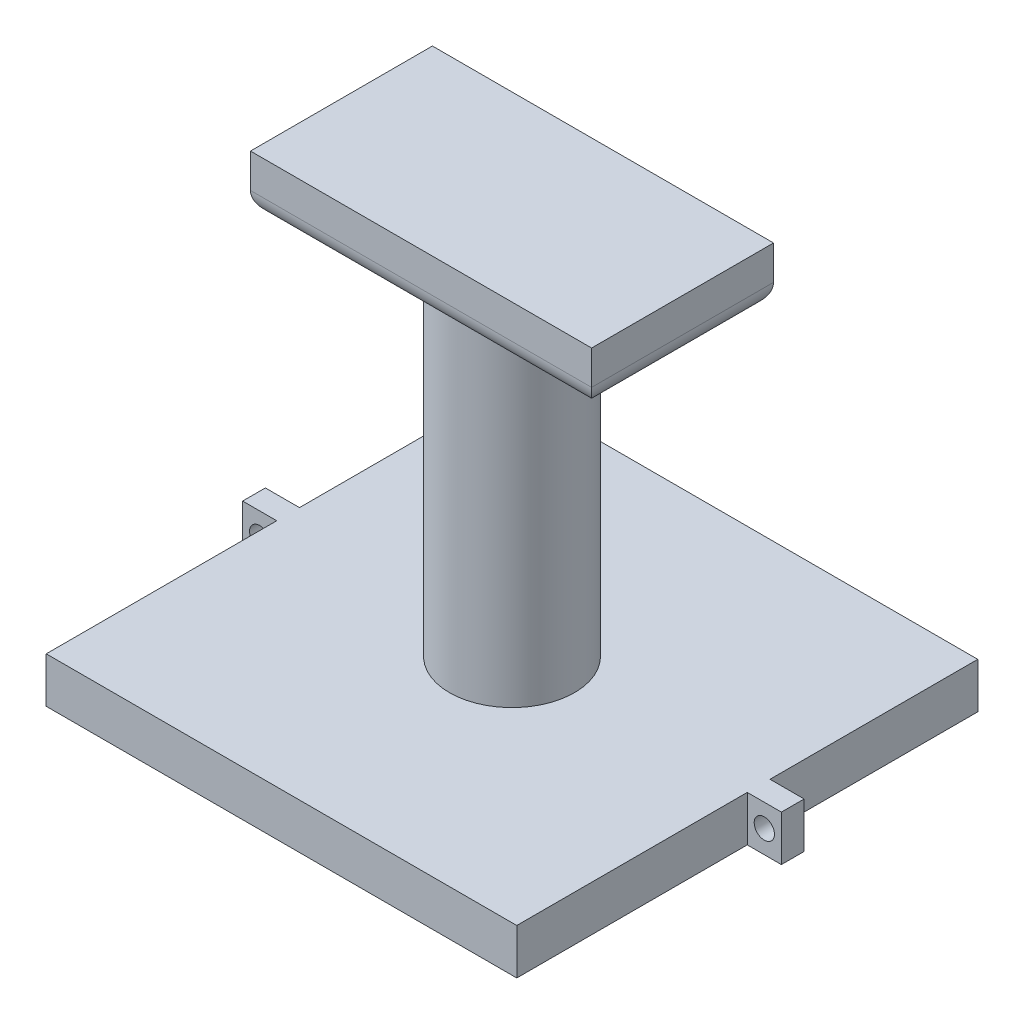
from build123d import *

# Parameters (mm, degrees)
SKETCH2_W           = 52.5507204
SKETCH2_H           = 51.48598542
SKETCH2_W_2         = 3.81
SKETCH2_H_2         = 2.54
BOSS_EXTRUDE1_DEPTH = 5.08
SKETCH3_W           = 47.4707204
SKETCH3_H           = 46.40598542
CUT_EXTRUDE1_DEPTH  = 3.81
SKETCH4_R           = 1.1303
CUT_EXTRUDE2_DEPTH  = 3.302
SKETCH5_R           = 5.08
CUT_EXTRUDE3_DEPTH  = 1.9304
SKETCH6_R           = 6.985
BOSS_EXTRUDE2_DEPTH = 38.1
SKETCH8_R           = 5.08
CUT_EXTRUDE4_DEPTH  = 38.1
SKETCH7_W           = 38.1
SKETCH7_H           = 20.32
BOSS_EXTRUDE3_DEPTH = 6.35
FILLET3_R           = 2.54


with BuildPart() as part:
    # Sketch2 → Boss-Extrude1 (new body)
    with BuildSketch(Plane(origin=(0, 0, 0), x_dir=(1, 0, 0), z_dir=(0, 1, 0))):
        with Locations((0, 3.81e-06)):
            Rectangle(SKETCH2_W, SKETCH2_H)
        with Locations((28.1803602, 1.27)):
            Rectangle(SKETCH2_W_2, SKETCH2_H_2)
        with Locations((-28.1803602, 1.2700127)):
            Rectangle(SKETCH2_W_2, SKETCH2_H_2)
    extrude(amount=BOSS_EXTRUDE1_DEPTH)

    # Sketch3 → Cut-Extrude1 (cut)
    with BuildSketch(Plane.XZ):
        with Locations((0, -3.81e-06)):
            Rectangle(SKETCH3_W, SKETCH3_H)
    extrude(amount=-CUT_EXTRUDE1_DEPTH, mode=Mode.SUBTRACT)

    # Sketch4 → Cut-Extrude2 (cut)
    with BuildSketch(Plane.XY):
        with Locations((28.1803602, 2.54)):
            Circle(SKETCH4_R)
        with Locations((-28.1803602, 2.54)):
            Circle(SKETCH4_R)
    extrude(amount=-CUT_EXTRUDE2_DEPTH, mode=Mode.SUBTRACT)

    # Sketch5 → Cut-Extrude3 (cut)
    with BuildSketch(Plane(origin=(0, 5.08, 0), x_dir=(1, 0, 0), z_dir=(0, 1, 0))):
        Circle(SKETCH5_R)
    extrude(amount=-CUT_EXTRUDE3_DEPTH, mode=Mode.SUBTRACT)

    # Sketch6 → Boss-Extrude2 (add)
    with BuildSketch(Plane(origin=(0, 5.08, 0), x_dir=(1, 0, 0), z_dir=(0, 1, 0))):
        Circle(SKETCH6_R)
    extrude(amount=BOSS_EXTRUDE2_DEPTH)

    # Sketch8 → Cut-Extrude4 (cut)
    with BuildSketch(Plane(origin=(0, 43.18, 0), x_dir=(1, 0, 0), z_dir=(0, 1, 0))):
        Circle(SKETCH8_R)
    extrude(amount=-CUT_EXTRUDE4_DEPTH, mode=Mode.SUBTRACT)

    # Sketch7 → Boss-Extrude3 (add)
    with BuildSketch(Plane(origin=(0, 43.18, 0), x_dir=(1, 0, 0), z_dir=(0, 1, 0))):
        Rectangle(SKETCH7_W, SKETCH7_H)
    extrude(amount=BOSS_EXTRUDE3_DEPTH)

    # Fillet3
    fillet3_edges = [part.edges().sort_by_distance(p)[0] for p in [
        (-19.05, 43.18, 0),
        (0, 43.18, 10.16),
        (19.05, 43.18, 0),
        (0, 43.18, -10.16),
    ]]
    fillet(fillet3_edges, radius=FILLET3_R)


solid = part.part
